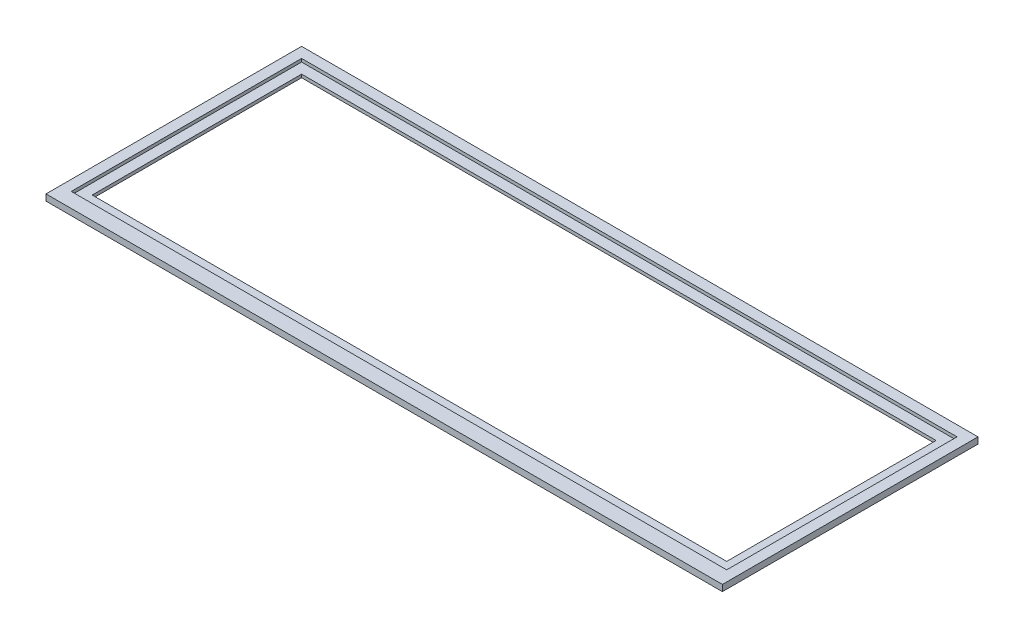
from build123d import *

# Parameters (mm, degrees)
SKETCH1_W               = 323
SKETCH1_H               = 120
BOSS_EXTRUDE1_DEPTH     = 3
SKETCH2_W               = 313
SKETCH2_H               = 110
SKETCH2_W_2             = 303
SKETCH2_H_2             = 100
CUT_EXTRUDE2_DEPTH      = 1.5
SKETCH2_4_W             = 303
SKETCH2_4_H             = 100
CUT_EXTRUDE3_DEPTH      = 1
CUT_EXTRUDE3_DEPTH_BACK = 4
SKETCH3_W               = 323
SKETCH3_H               = 2.051483501
BOSS_EXTRUDE2_DEPTH     = 3


with BuildPart() as part:
    # Sketch1 → Boss-Extrude1 (new body)
    with BuildSketch(Plane(origin=(0, 0, 0), x_dir=(1, 0, 0), z_dir=(0, 1, 0))):
        Rectangle(SKETCH1_W, SKETCH1_H)
    extrude(amount=BOSS_EXTRUDE1_DEPTH)

    # Sketch2 → Cut-Extrude2 (cut)
    with BuildSketch(Plane(origin=(0, 3, 0), x_dir=(1, 0, 0), z_dir=(0, 1, 0))):
        Rectangle(SKETCH2_W, SKETCH2_H)
        Rectangle(SKETCH2_W_2, SKETCH2_H_2, mode=Mode.SUBTRACT)
    extrude(amount=-CUT_EXTRUDE2_DEPTH, mode=Mode.SUBTRACT)

    # Sketch2_4 → Cut-Extrude3 (cut, two sides)
    with BuildSketch(Plane(origin=(0, 3, 0), x_dir=(1, 0, 0), z_dir=(0, 1, 0))) as cut_extrude3_sk:
        Rectangle(SKETCH2_4_W, SKETCH2_4_H)
    extrude(amount=CUT_EXTRUDE3_DEPTH, mode=Mode.SUBTRACT)
    extrude(cut_extrude3_sk.sketch, amount=-CUT_EXTRUDE3_DEPTH_BACK, mode=Mode.SUBTRACT)

    # Sketch3 → Boss-Extrude2 (add)
    with BuildSketch(Plane(origin=(0, 3, 0), x_dir=(1, 0, 0), z_dir=(0, 1, 0))):
        with Locations((0, -61.025741751)):
            Rectangle(SKETCH3_W, SKETCH3_H)
    extrude(amount=-BOSS_EXTRUDE2_DEPTH)


solid = part.part
